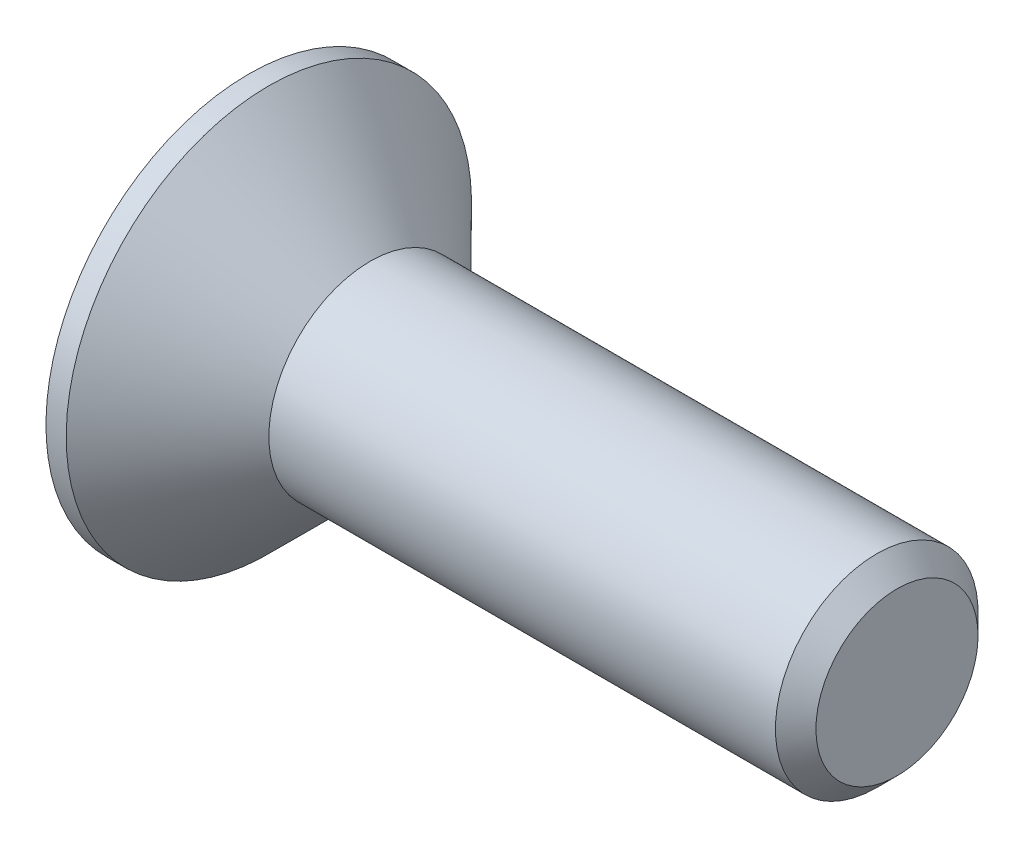
from build123d import *

# Parameters (mm, degrees)
CHANFREIN1_SIZE         = 0.5
ENL_V_MAT_EXTRU_1_DEPTH = 2.3


with BuildPart() as part:
    # Esquisse1 → Révolution1 (revolve)
    with BuildSketch(Plane.XY):
        Polygon((0, 0), (0, 5), (0.5, 5), (3, 2.5), (16, 2.5), (16, 0), align=None)
    revolve(axis=Axis((16, 0, 0), (-1, 0, 0)))

    # Chanfrein1
    chanfrein1_edges = [part.edges().sort_by_distance(p)[0] for p in [
        (16, -2.5, 0),
    ]]
    chamfer(chanfrein1_edges, length=CHANFREIN1_SIZE)

    # Esquisse2 → Enlèv. mat.-Extru.1 (cut)
    with BuildSketch(Plane.ZY):
        Polygon((0, 1.732050808), (-1.5, 0.866025404), (-1.5, -0.866025404), (0, -1.732050808), (1.5, -0.866025404), (1.5, 0.866025404), align=None)
    extrude(amount=-ENL_V_MAT_EXTRU_1_DEPTH, mode=Mode.SUBTRACT)


solid = part.part
